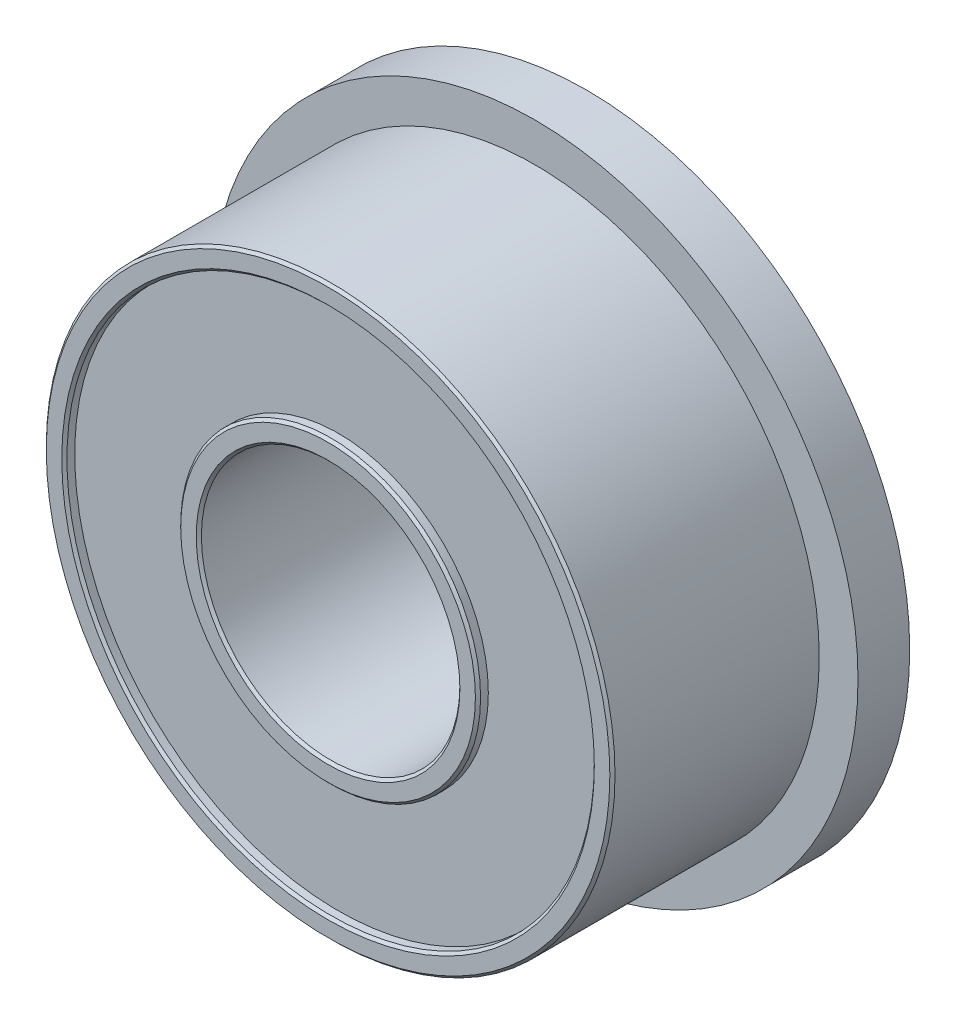
from build123d import *

# Parameters (mm, degrees)
SKETCH_1_R          = 5.5
SKETCH_1_R_2        = 2.5
EXTRUDE_1_DEPTH     = 2.5
SKETCH_3_R          = 6.25
SKETCH_3_R_2        = 2.5
EXTRUDE_2_DEPTH     = 1
SKETCH_4_R          = 5.1
SKETCH_4_R_2        = 2.9
CUT_EXTRUDE_1_DEPTH = 0.2
CHAMFER_1_SIZE      = 0.05


with BuildPart() as part:
    # 草图1 → 凸台-拉伸1 (new body, symmetric)
    with BuildSketch(Plane.XY):
        Circle(SKETCH_1_R)
        Circle(SKETCH_1_R_2, mode=Mode.SUBTRACT)
    extrude(amount=EXTRUDE_1_DEPTH, both=True)

    # 草图3 → 凸台-拉伸2 (add)
    with BuildSketch(Plane(origin=(0, 0, -2.5), x_dir=(-1, 0, 0), z_dir=(0, 0, -1))):
        Circle(SKETCH_3_R)
        Circle(SKETCH_3_R_2, mode=Mode.SUBTRACT)
    extrude(amount=-EXTRUDE_2_DEPTH)

    # 草图4 → 切除-拉伸1 (cut)
    with BuildSketch(Plane.XY.offset(2.5)):
        Circle(SKETCH_4_R)
        Circle(SKETCH_4_R_2, mode=Mode.SUBTRACT)
    cut_extrude_1 = extrude(amount=-CUT_EXTRUDE_1_DEPTH, mode=Mode.SUBTRACT)

    # 镜向1: 切除-拉伸1 across plane
    add(cut_extrude_1.mirror(Plane.XY), mode=Mode.SUBTRACT)

    # 倒角1
    chamfer_1_edges = [part.edges().sort_by_distance(p)[0] for p in [
        (-5.1, 0, 2.5),
        (-2.9, 0, 2.5),
        (-2.9, 0, -2.5),
        (-5.1, 0, -2.5),
        (-5.5, 0, 2.5),
        (-2.5, 0, -2.5),
        (-2.5, 0, 2.5),
    ]]
    chamfer(chamfer_1_edges, length=CHAMFER_1_SIZE)


solid = part.part
